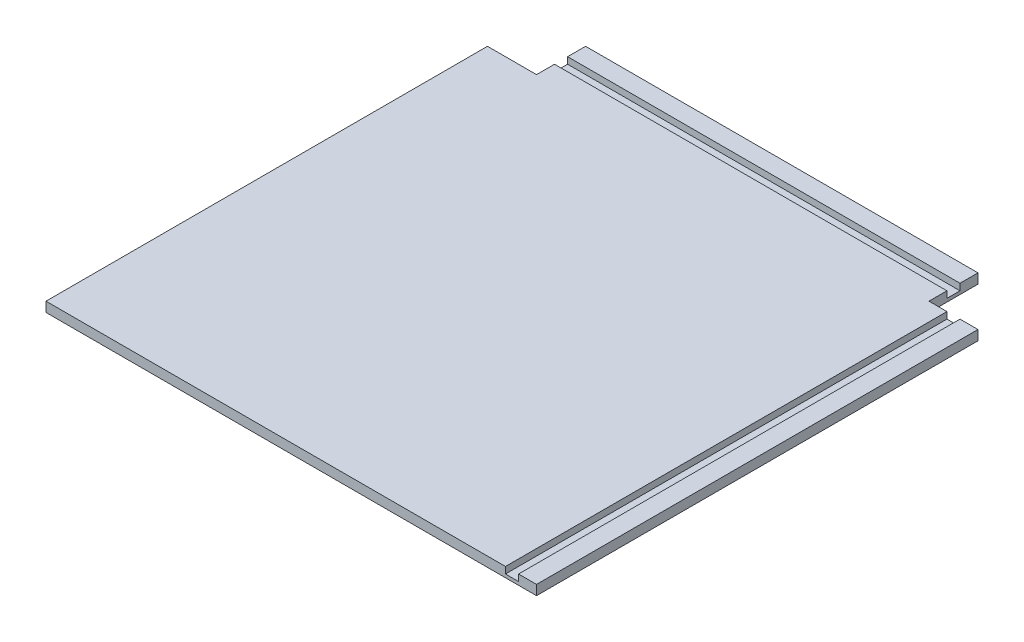
from build123d import *

# Parameters (mm, degrees)
BOSS_EXTRUDE1_DEPTH = 15
SKETCH3_W           = 20
SKETCH3_H           = 10
CUT_EXTRUDE1_DEPTH  = 675
SKETCH4_W           = 20
SKETCH4_H           = 10
CUT_EXTRUDE2_DEPTH  = 751


with BuildPart() as part:
    # Sketch2 → Boss-Extrude1 (new body)
    with BuildSketch(Plane(origin=(0, 0, 0), x_dir=(1, 0, 0), z_dir=(0, 1, 0))):
        Polygon((-375, 300), (-375, -375), (375, -375), (375, 300), (300, 300), (300, 375), (-300, 375), (-300, 300), align=None)
    extrude(amount=BOSS_EXTRUDE1_DEPTH)

    # Sketch3 → Cut-Extrude1 (cut)
    with BuildSketch(Plane.XY.offset(375)):
        with Locations((337.5, 10)):
            Rectangle(SKETCH3_W, SKETCH3_H)
    extrude(amount=-CUT_EXTRUDE1_DEPTH, mode=Mode.SUBTRACT)

    # Sketch4 → Cut-Extrude2 (cut, through all)
    with BuildSketch(Plane(origin=(375, 0, 0), x_dir=(0, 0, -1), z_dir=(1, 0, 0))):
        with Locations((337.5, 10)):
            Rectangle(SKETCH4_W, SKETCH4_H)
    extrude(amount=-CUT_EXTRUDE2_DEPTH, mode=Mode.SUBTRACT)


solid = part.part
